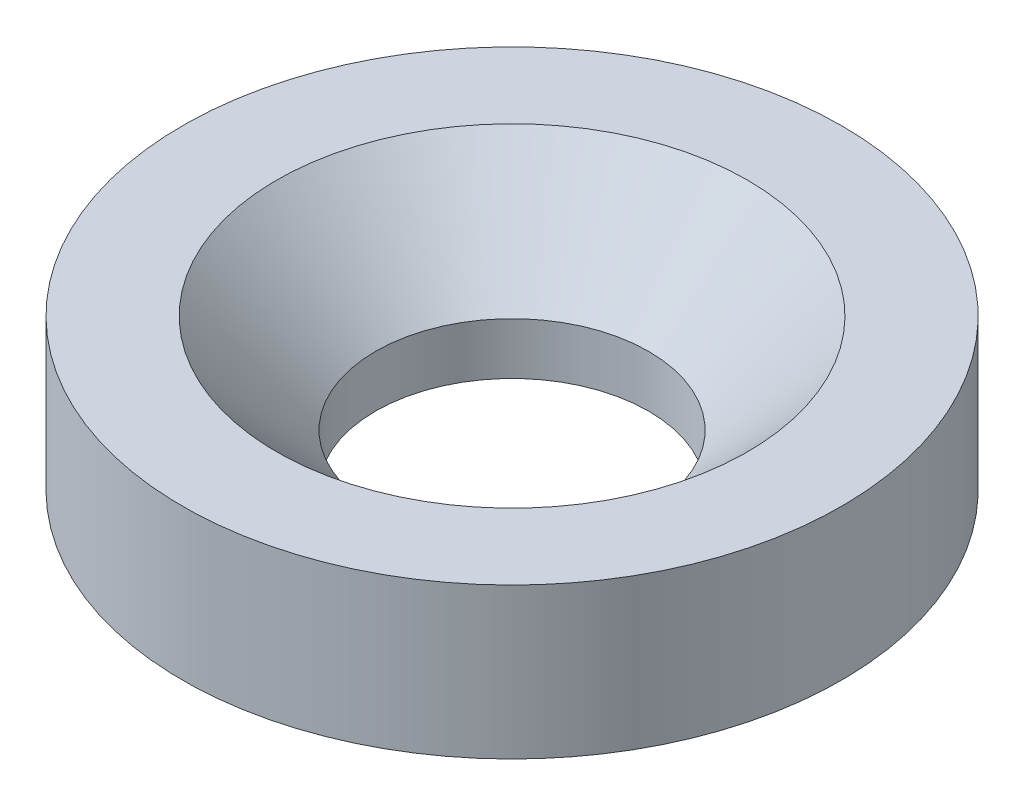
from build123d import *


with BuildPart() as part:
    # Sketch1 → Revolve1 (revolve)
    with BuildSketch(Plane.XY):
        Polygon((7.25, 0), (17.5, 0), (17.5, 8), (12.5, 8), (7.25, 2.75), align=None)
    revolve(axis=Axis((0, 0, 0), (0, 1, 0)))


solid = part.part
